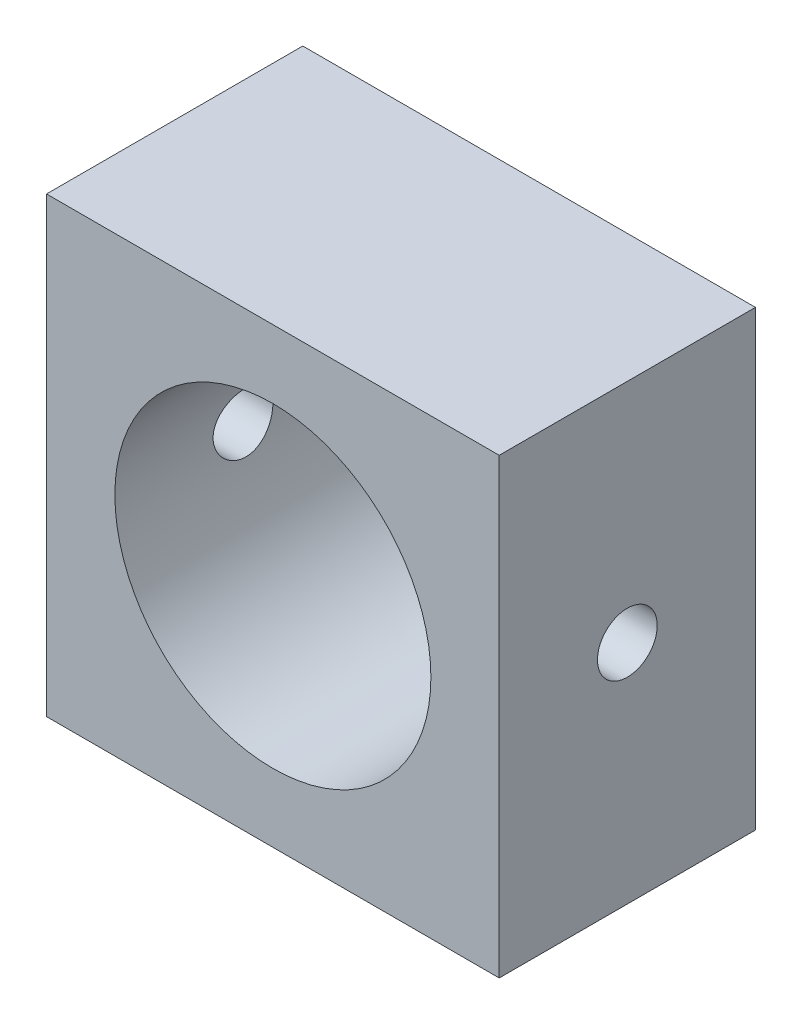
from build123d import *

# Parameters (mm, degrees)
SKETCH_1_W               = 26.5
SKETCH_1_H               = 26.5
SKETCH_1_R               = 9.25
EXTRUDE_1_DEPTH          = 7.5
SKETCH_3_R               = 1.75
CUT_EXTRUDE_1_DEPTH      = 14.25
CUT_EXTRUDE_1_DEPTH_BACK = 14.25


with BuildPart() as part:
    # ｽｹｯﾁ1 → ﾎﾞｽ - 押し出し1 (new body, symmetric)
    with BuildSketch(Plane.XY):
        Rectangle(SKETCH_1_W, SKETCH_1_H)
        Circle(SKETCH_1_R, mode=Mode.SUBTRACT)
    extrude(amount=EXTRUDE_1_DEPTH, both=True)

    # ｽｹｯﾁ3 → ｶｯﾄ - 押し出し1 (cut, two sides)
    with BuildSketch(Plane(origin=(0, 0, 0), x_dir=(0, 0, -1), z_dir=(1, 0, 0))) as cut_extrude_1_sk:
        Circle(SKETCH_3_R)
    extrude(amount=CUT_EXTRUDE_1_DEPTH, mode=Mode.SUBTRACT)
    extrude(cut_extrude_1_sk.sketch, amount=-CUT_EXTRUDE_1_DEPTH_BACK, mode=Mode.SUBTRACT)


solid = part.part
